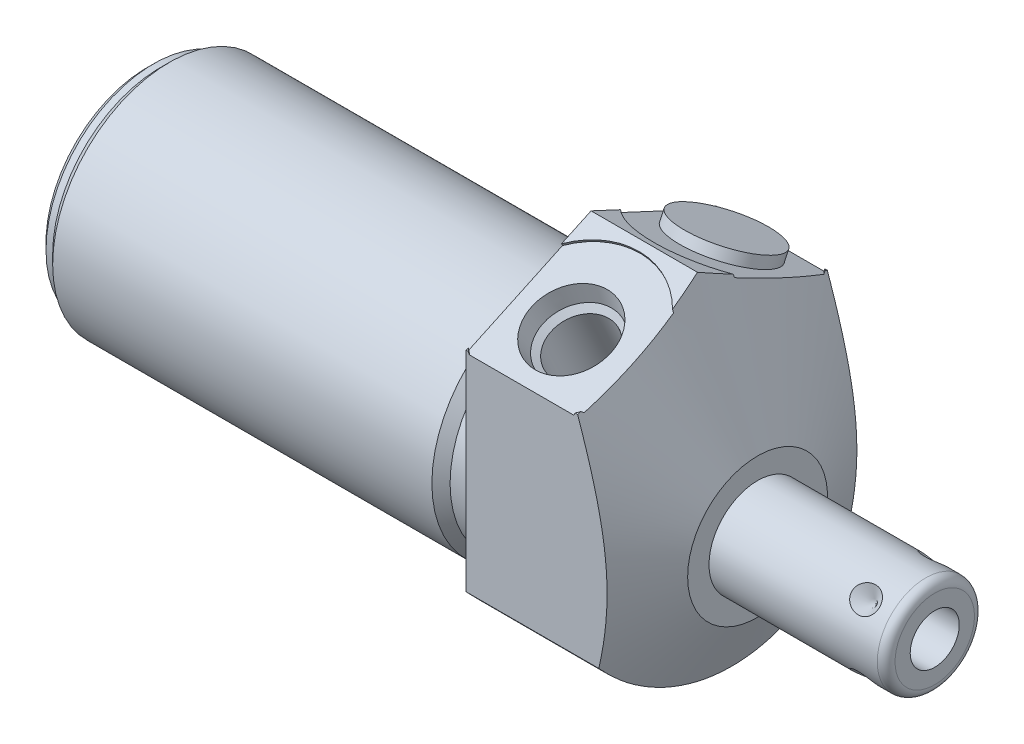
from build123d import *

# Parameters (mm, degrees)
SKETCH1_R           = 19.05
EXTRUDE1_DEPTH      = 19.05
EXTRUDE1_DEPTH_BACK = 50.8
CUT_EXTRUDE1_REACH  = 52.8
SKETCH2_R           = 19.05
SKETCH2_R_2         = 13.3604
CUT_EXTRUDE3_REACH  = 21.05
SKETCH19_R          = 8.6614
CUT_EXTRUDE4_DEPTH  = 0.254
SKETCH20_R          = 8.6614
CUT_EXTRUDE5_DEPTH  = 0.254
CHAMFER1_SIZE       = 0.762
SKETCH15_R          = 5.3086
EXTRUDE2_DEPTH      = 1.27
CIRPATTERN1_COUNT   = 4


with BuildPart() as part:
    # Sketch1 → Extrude1 (new body, two sides)
    with BuildSketch(Plane(origin=(0, 0, 0), x_dir=(0, 0, -1), z_dir=(1, 0, 0))) as extrude1_sk:
        Circle(SKETCH1_R)
    extrude(amount=EXTRUDE1_DEPTH)
    extrude(extrude1_sk.sketch, amount=-EXTRUDE1_DEPTH_BACK)

    # Sketch2 → Cut-Extrude1 (cut, up to next)
    with BuildSketch(Plane(origin=(0, 0, 0), x_dir=(0, 0, -1), z_dir=(1, 0, 0)), mode=Mode.PRIVATE) as cut_extrude1_sk1:
        Circle(SKETCH2_R)
        with Locations((0, -4.7498)):
            Circle(SKETCH2_R_2, mode=Mode.SUBTRACT)
    cut_extrude1_tool1 = extrude(cut_extrude1_sk1.sketch, amount=-CUT_EXTRUDE1_REACH, mode=Mode.PRIVATE) & part.part
    add(cut_extrude1_tool1.solids().sort_by_distance((0, 0, 18.511185))[0], mode=Mode.SUBTRACT)

    # Sketch4 → Cut-Extrude3 (cut, up to next)
    with BuildSketch(Plane.ZY, mode=Mode.PRIVATE) as cut_extrude3_sk1:
        with BuildLine():
            Line((14.2875, -12.600390619), (14.2875, 11.344778237))
            Line((14.2875, 11.344778237), (0, 18.007148903))
            Line((0, 18.007148903), (-14.2875, 11.344778237))
            Line((-14.2875, 11.344778237), (-14.2875, -12.600390619))
            ThreePointArc((-14.2875, -12.600390619), (0, 19.05), (14.2875, -12.600390619))
        make_face()
    cut_extrude3_tool1 = extrude(cut_extrude3_sk1.sketch, amount=-CUT_EXTRUDE3_REACH, mode=Mode.PRIVATE) & part.part
    add(cut_extrude3_tool1.solids().sort_by_distance((0, -0.627806, 14.782814))[0], mode=Mode.SUBTRACT)

    # Sketch6 → Cut-Revolve2 (revolve, cut)
    with BuildSketch(Plane.XY, mode=Mode.PRIVATE) as cut_revolve2_sk:
        Polygon((12.169188023, 18.007148903), (19.05, 3.2512), (19.05, 18.007148903), align=None)
    revolve(cut_revolve2_sk.sketch.rotate(Axis((1.987224567, -4.7498, 0), (1, 0, 0)), 270), axis=Axis((1.987224567, -4.7498, 0), (1, 0, 0)), mode=Mode.SUBTRACT)  # turned: the seam where the file's is

    # S2D0002 → Cut-Revolve3 (revolve, cut)
    with BuildSketch(Plane(origin=(6.35, 13.712414668, 8.609072086), x_dir=(0, 0.422618262, -0.906307787), z_dir=(1, 0, 0))):
        Polygon((0, 0), (4.5466, 0), (4.106586662, -2.0701), (3.4544, -2.722286662), (3.4544, -12.192), (0, -12.192), align=None)
    revolve(axis=Axis((6.35, 2.110224902, 3.198882147), (0, 0.906307787, 0.422618262)), mode=Mode.SUBTRACT)

    # Sketch19 → Cut-Extrude4 (cut)
    with BuildSketch(Plane(origin=(0, 14.790960552, 6.897138177), x_dir=(1, 0, 0), z_dir=(0, 0.906307787, 0.422618262))):
        with Locations((6.35, -2.00735222)):
            Circle(SKETCH19_R)
    extrude(amount=-CUT_EXTRUDE4_DEPTH, mode=Mode.SUBTRACT)

    # Sketch8 → Cut-Revolve4 (revolve, cut)
    with BuildSketch(Plane(origin=(6.35, 13.712414668, -8.609072086), x_dir=(0, -0.422618262, -0.906307787), z_dir=(1, 0, 0))):
        Polygon((0, 0), (4.5466, 0), (4.106586662, -2.0701), (3.4544, -2.722286662), (3.4544, -12.192), (0, -12.192), align=None)
    revolve(axis=Axis((6.35, 2.110224902, -3.198882147), (0, 0.906307787, -0.422618262)), mode=Mode.SUBTRACT)

    # Sketch20 → Cut-Extrude5 (cut)
    with BuildSketch(Plane(origin=(0, 14.790960552, -6.897138177), x_dir=(1, 0, 0), z_dir=(0, 0.906307787, -0.422618262))):
        with Locations((6.35, 2.00735222)):
            Circle(SKETCH20_R)
    extrude(amount=-CUT_EXTRUDE5_DEPTH, mode=Mode.SUBTRACT)

    # Sketch10 → Cut-Revolve6 (revolve, cut)
    with BuildSketch(Plane.XY, mode=Mode.PRIVATE) as cut_revolve6_sk:
        Polygon((0, 8.6106), (0, 7.5692), (-3.81, 7.5692), (-4.8514, 8.6106), align=None)
    revolve(cut_revolve6_sk.sketch.rotate(Axis((-5.09397, -4.7498, 0), (1, 0, 0)), 90), axis=Axis((-5.09397, -4.7498, 0), (1, 0, 0)), mode=Mode.SUBTRACT)  # turned: the seam where the file's is

    # Sketch12 → Cut-Revolve8 (revolve, cut)
    with BuildSketch(Plane.XY, mode=Mode.PRIVATE) as cut_revolve8_sk:
        Polygon((-50.8, 8.6106), (-50.8, 7.5692), (-49.276, 7.5692), (-48.2346, 8.6106), align=None)
    revolve(cut_revolve8_sk.sketch.rotate(Axis((-50.92827, -4.7498, 0), (1, 0, 0)), 90), axis=Axis((-50.92827, -4.7498, 0), (1, 0, 0)), mode=Mode.SUBTRACT)  # turned: the seam where the file's is

    # Chamfer1
    chamfer1_edges = [part.edges().sort_by_distance(p)[0] for p in [
        (-50.8, -4.7498, -12.319),
    ]]
    chamfer(chamfer1_edges, length=CHAMFER1_SIZE)

    # Sketch13 → Revolve1 (revolve)
    with BuildSketch(Plane(origin=(0, 0, 0), x_dir=(0, -1, 0), z_dir=(0, 0, 1)), mode=Mode.PRIVATE) as revolve1_sk:
        with BuildLine():
            Line((4.7498, 19.05), (4.7498, 39.3192))
            Line((4.7498, 39.3192), (9.29005, 39.3192))
            ThreePointArc((9.29005, 39.3192), (10.00847049, 39.02162049), (10.30605, 38.3032))
            Line((10.30605, 38.3032), (10.30605, 19.05))
            Line((10.30605, 19.05), (4.7498, 19.05))
        make_face()
    revolve(revolve1_sk.sketch.rotate(Axis((18.03654, -4.7498, 0), (1, 0, 0)), 270), axis=Axis((18.03654, -4.7498, 0), (1, 0, 0)))  # turned: the seam where the file's is

    # S2D0001 → Cut-Revolve9 (revolve, cut)
    with BuildSketch(Plane(origin=(39.3192, -7.5565, 0), x_dir=(0, -1, 0), z_dir=(0, 0, 1)), mode=Mode.PRIVATE) as cut_revolve9_sk:
        Polygon((0, 0), (0, -10.16), (-2.8067, -11.846435499), (-2.8067, 0), align=None)
    revolve(cut_revolve9_sk.sketch.rotate(Axis((26.880442726, -4.7498, 0), (1, 0, 0)), 270), axis=Axis((26.880442726, -4.7498, 0), (1, 0, 0)), mode=Mode.SUBTRACT)  # turned: the seam where the file's is

    # Sketch15 → Extrude2 (add)
    with BuildSketch(Plane(origin=(19.05, 14.560758374, -6.789793138), x_dir=(0, -0.422618262, -0.906307787), z_dir=(0, -0.906307787, 0.422618262))):
        with Locations((2.00735222, -12.7)):
            Circle(SKETCH15_R)
    extrude(amount=-EXTRUDE2_DEPTH)

    # Sketch16 → Cut-Revolve10 (revolve, cut)
    with BuildSketch(Plane(origin=(35.3568, -0.820937947, -3.928862053), x_dir=(-1, 0, 0), z_dir=(0, -0.707106781, -0.707106781)), mode=Mode.PRIVATE) as cut_revolve10_sk:
        Polygon((0, 0), (1.5875, 0), (0, -1.5875), align=None)
    cut_revolve10 = revolve(cut_revolve10_sk.sketch.rotate(Axis((35.3568, -3.280818463, -1.468981537), (0, 0.707106781, -0.707106781)), 90), axis=Axis((35.3568, -3.280818463, -1.468981537), (0, 0.707106781, -0.707106781)), mode=Mode.SUBTRACT)  # turned: the seam where the file's is

    # CirPattern1: Cut-Revolve10 ×4 about axis
    cirpattern1_axis = Axis((18.03654, -4.7498, 0), (-1, 0, 0))
    for i in range(1, CIRPATTERN1_COUNT):
        add(cut_revolve10.rotate(cirpattern1_axis, i * 360 / CIRPATTERN1_COUNT), mode=Mode.SUBTRACT)


solid = part.part
